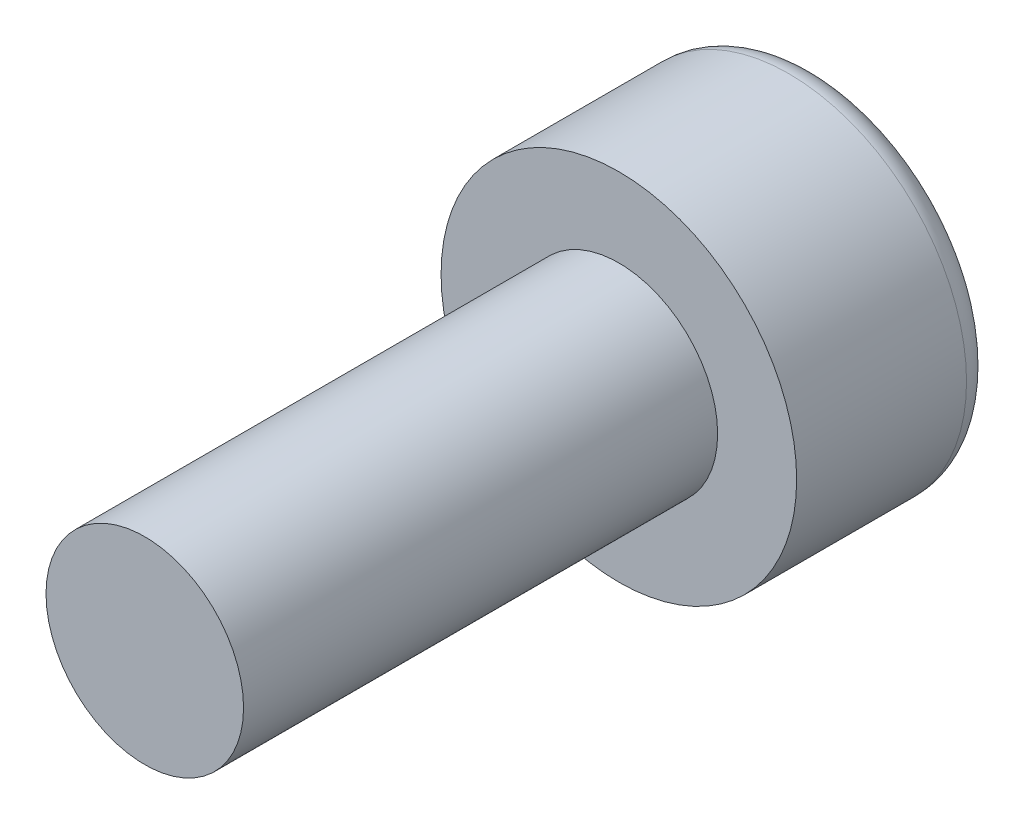
from build123d import *

# Parameters (mm, degrees)
CROQUIS1_R              = 1.25
SALIENTE_EXTRUIR1_DEPTH = 6
CROQUIS2_R              = 2.25
SALIENTE_EXTRUIR2_DEPTH = 2.5
CORTAR_EXTRUIR1_DEPTH   = 1.5
REDONDEO1_R             = 0.35


with BuildPart() as part:
    # Croquis1 → Saliente-Extruir1 (new body)
    with BuildSketch(Plane.XY):
        Circle(CROQUIS1_R)
    extrude(amount=SALIENTE_EXTRUIR1_DEPTH)

    # Croquis2 → Saliente-Extruir2 (add)
    with BuildSketch(Plane(origin=(0, 0, 0), x_dir=(-1, 0, 0), z_dir=(0, 0, -1))):
        Circle(CROQUIS2_R)
    extrude(amount=SALIENTE_EXTRUIR2_DEPTH)

    # Croquis3 → Cortar-Extruir1 (cut)
    with BuildSketch(Plane(origin=(0, 0, -2.5), x_dir=(-1, 0, 0), z_dir=(0, 0, -1))):
        Polygon((0, -1.154700538), (1, -0.577350269), (1, 0.577350269), (0, 1.154700538), (-1, 0.577350269), (-1, -0.577350269), align=None)
    extrude(amount=-CORTAR_EXTRUIR1_DEPTH, mode=Mode.SUBTRACT)

    # Redondeo1
    redondeo1_edges = [part.edges().sort_by_distance(p)[0] for p in [
        (2.25, 0, -2.5),
    ]]
    fillet(redondeo1_edges, radius=REDONDEO1_R)


solid = part.part
